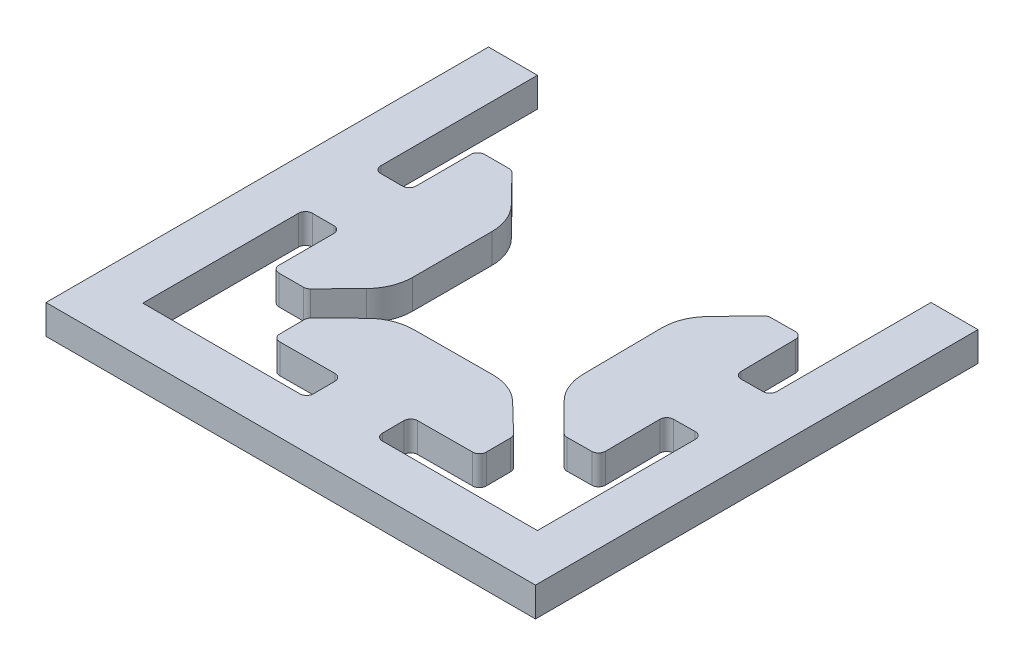
from build123d import *

# Parameters (mm, degrees)
BOSS_EXTRUDE1_DEPTH = 3
FILLET4_R           = 0.7
FILLET5_R           = 4.8


with BuildPart() as part:
    # Sketch1 → Boss-Extrude1 (new body)
    with BuildSketch(Plane(origin=(0, 0, 0), x_dir=(1, 0, 0), z_dir=(0, 1, 0))):
        Polygon((-25, -25), (25, -25), (25, 20.2), (20.2, 20.2), (20.2, 3.75), (16.600191324, 3.712885357), (16.528023963, 10.712513338), (13.028209972, 10.676429657), (8.674837116, 6.131306471), (8.798552593, -5.868055782), (13.244712056, -10.322454286), (16.744526047, -10.286370605), (16.672358686, -3.286742624), (20.272167361, -3.249627981), (20.272167361, -20.078881527), (3.743734852, -20.078881527), (3.725177284, -16.478929358), (10.725084279, -16.442845198), (10.707042199, -12.942891701), (6.184420516, -8.566147121), (-5.815420046, -8.628005682), (-10.292678785, -13.051144181), (-10.274636705, -16.551097679), (-3.27472971, -16.515013518), (-3.256172142, -20.114965687), (-20, -20.114965687), (-20, -3.5), (-16.4, -3.5), (-16.4, -10.5), (-12.9, -10.5), (-8.5, -6), (-8.5, 6), (-12.9, 10.5), (-16.4, 10.5), (-16.4, 3.5), (-20, 3.5), (-20, 20.2), (-25, 20.2), align=None)
    extrude(amount=BOSS_EXTRUDE1_DEPTH)

    # Fillet4
    fillet4_edges = [part.edges().sort_by_distance(p)[0] for p in [
        (-3.27472971, 1.5, 16.515013518),
        (-10.274636705, 1.5, 16.551097679),
        (-10.292678785, 1.5, 13.051144181),
        (10.707042199, 1.5, 12.942891701),
        (10.725084279, 1.5, 16.442845198),
        (3.725177284, 1.5, 16.478929358),
        (3.743734852, 1.5, 20.078881527),
        (20.272167361, 1.5, 3.249627981),
        (16.672358686, 1.5, 3.286742624),
        (16.744526047, 1.5, 10.286370605),
        (13.244712056, 1.5, 10.322454286),
        (13.028209972, 1.5, -10.676429657),
        (16.528023963, 1.5, -10.712513338),
        (16.600191324, 1.5, -3.712885357),
        (20.2, 1.5, -3.75),
        (-20, 1.5, -3.5),
        (-16.4, 1.5, -3.5),
        (-16.4, 1.5, -10.5),
        (-12.9, 1.5, -10.5),
        (-12.9, 1.5, 10.5),
        (-16.4, 1.5, 10.5),
        (-16.4, 1.5, 3.5),
        (-20, 1.5, 3.5),
        (-3.256172142, 1.5, 20.114965687),
    ]]
    fillet(fillet4_edges, radius=FILLET4_R)

    # Fillet5
    fillet5_edges = [part.edges().sort_by_distance(p)[0] for p in [
        (-5.815420046, 1.5, 8.628005682),
        (6.184420516, 1.5, 8.566147121),
        (8.798552593, 1.5, 5.868055782),
        (8.674837116, 1.5, -6.131306471),
        (-8.5, 1.5, -6),
        (-8.5, 1.5, 6),
    ]]
    fillet(fillet5_edges, radius=FILLET5_R)


solid = part.part
